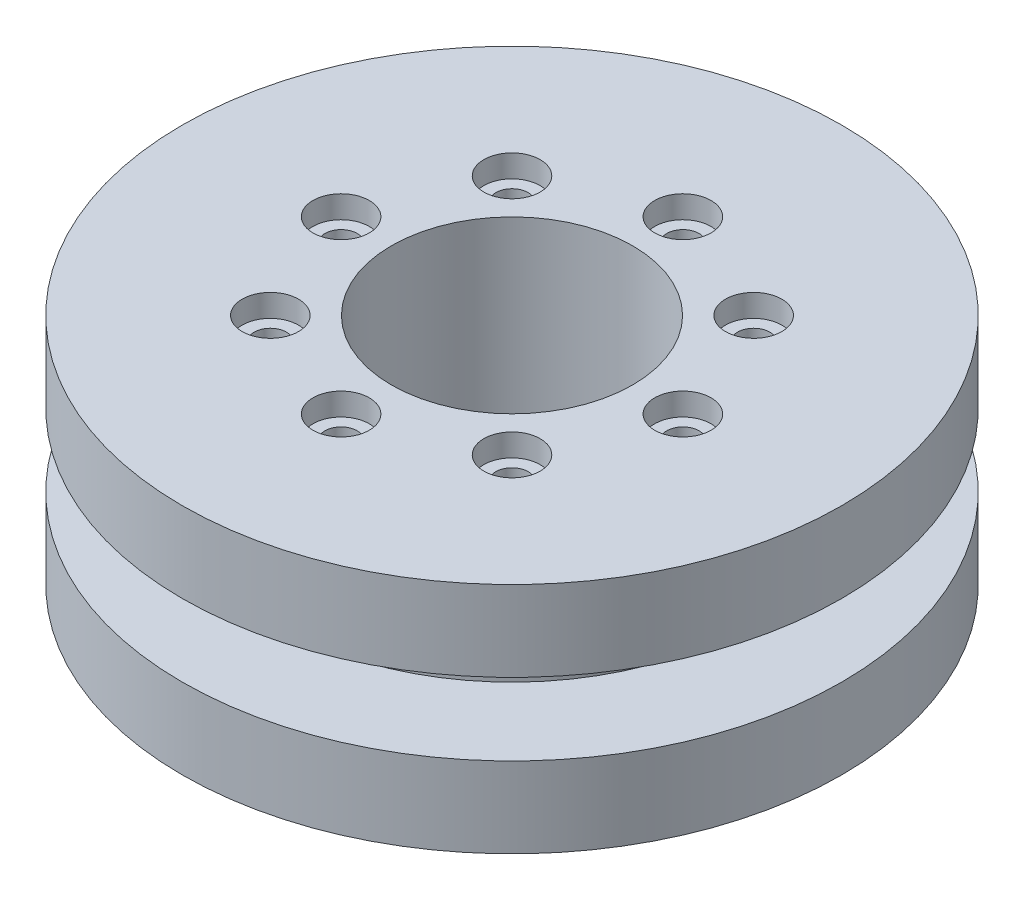
from build123d import *

# Parameters (mm, degrees)
SKETCH1_R           = 41
SKETCH1_R_2         = 15
BOSS_EXTRUDE1_DEPTH = 14.5
SKETCH3_W           = 12
SKETCH3_H           = 9
HOLE1_D             = 4
HOLE1_CBORE_D       = 7
HOLE1_CBORE_DEPTH   = 2.8
CIRPATTERN1_COUNT   = 8


with BuildPart() as part:
    # Sketch1 → Boss-Extrude1 (new body, symmetric)
    with BuildSketch(Plane(origin=(0, 0, 0), x_dir=(1, 0, 0), z_dir=(0, 1, 0))):
        Circle(SKETCH1_R)
        Circle(SKETCH1_R_2, mode=Mode.SUBTRACT)
    extrude(amount=BOSS_EXTRUDE1_DEPTH, both=True)

    # Sketch3 → Cut-Revolve1 (revolve, cut)
    with BuildSketch(Plane(origin=(0, 0, 0), x_dir=(0, 0, -1), z_dir=(1, 0, 0))):
        with Locations((35, 0)):
            Rectangle(SKETCH3_W, SKETCH3_H)
    revolve(axis=Axis((0, 14.5, 0), (0, -1, 0)), mode=Mode.SUBTRACT)

    # Hole1 (through all)
    with Locations(Plane(origin=(0, 14.5, -21.25), x_dir=(0, 0, 1), z_dir=(0, 1, 0))):
        with Locations((0, 0)):
            hole1 = CounterBoreHole(HOLE1_D / 2, HOLE1_CBORE_D / 2, HOLE1_CBORE_DEPTH)

    # CirPattern1: Hole1 ×8 about axis
    cirpattern1_axis = Axis((0, 0, 0), (0, 1, 0))
    for i in range(1, CIRPATTERN1_COUNT):
        add(hole1.rotate(cirpattern1_axis, i * 360 / CIRPATTERN1_COUNT), mode=Mode.SUBTRACT)


solid = part.part
